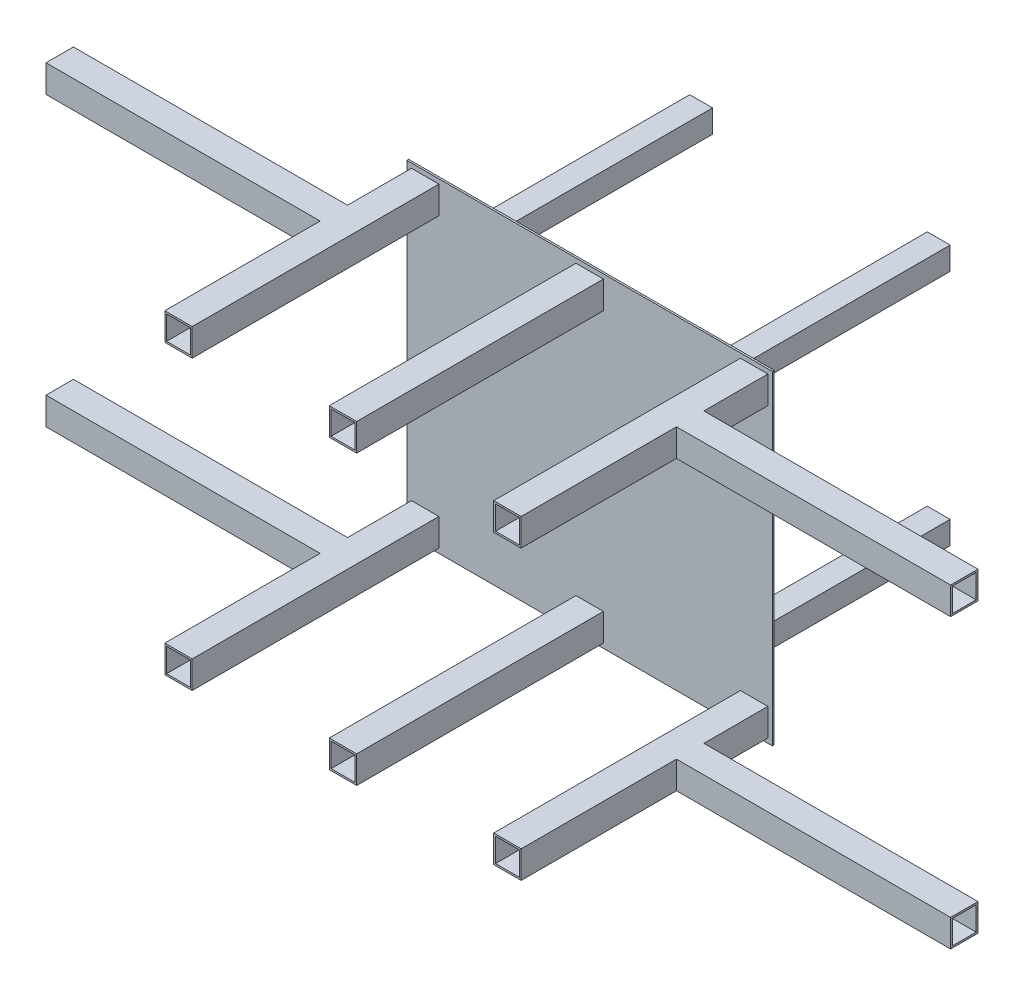
from build123d import *

# Parameters (mm, degrees)
SKETCH_1_W        = 30
SKETCH_1_H        = 30
SKETCH_1_W_2      = 26
SKETCH_1_H_2      = 26
EXTRUDE_1_DEPTH   = 270
EXTRUDE_1_2_DEPTH = 270
EXTRUDE_1_3_DEPTH = 270
EXTRUDE_1_4_DEPTH = 270
EXTRUDE_1_5_DEPTH = 270
EXTRUDE_1_6_DEPTH = 270
SKETCH_1_4_W      = 400
SKETCH_1_4_H      = 355
EXTRUDE_2_DEPTH   = 2
SKETCH_3_W        = 25
SKETCH_3_H        = 25
SKETCH_3_W_2      = 22
SKETCH_3_H_2      = 22
EXTRUDE_3_DEPTH   = 250
SKETCH_8_W        = 30
SKETCH_8_H        = 30
SKETCH_8_W_2      = 26
SKETCH_8_H_2      = 26
EXTRUDE_4_DEPTH   = 300


with BuildPart() as part:
    # 草圖1 → 填料-伸長1 (new body)
    with BuildSketch(Plane.XY):
        with Locations((-139.865693992, 17.660065035)):
            Rectangle(SKETCH_1_W, SKETCH_1_H)
        with Locations((-139.865693992, 17.660065035)):
            Rectangle(SKETCH_1_W_2, SKETCH_1_H_2, mode=Mode.SUBTRACT)
    extrude(amount=EXTRUDE_1_DEPTH)



with BuildPart() as body_2:
    # 草圖1 → Extrude 1 2 (new body)
    with BuildSketch(Plane.XY):
        with Locations((40.134306008, 17.660065035)):
            Rectangle(SKETCH_1_W, SKETCH_1_H)
        with Locations((40.134306008, 17.660065035)):
            Rectangle(SKETCH_1_W_2, SKETCH_1_H_2, mode=Mode.SUBTRACT)
    extrude(amount=EXTRUDE_1_2_DEPTH)


with BuildPart() as body_3:
    # 草圖1 → Extrude 1 3 (new body)
    with BuildSketch(Plane.XY):
        with Locations((220.134306008, 17.660065035)):
            Rectangle(SKETCH_1_W, SKETCH_1_H)
        with Locations((220.134306008, 17.660065035)):
            Rectangle(SKETCH_1_W_2, SKETCH_1_H_2, mode=Mode.SUBTRACT)
    extrude(amount=EXTRUDE_1_3_DEPTH)


with BuildPart() as body_4:
    # 草圖1 → Extrude 1 4 (new body)
    with BuildSketch(Plane.XY):
        with Locations((-139.865693992, -297.339934965)):
            Rectangle(SKETCH_1_W, SKETCH_1_H)
        with Locations((-139.865693992, -297.339934965)):
            Rectangle(SKETCH_1_W_2, SKETCH_1_H_2, mode=Mode.SUBTRACT)
    extrude(amount=EXTRUDE_1_4_DEPTH)


with BuildPart() as body_5:
    # 草圖1 → Extrude 1 5 (new body)
    with BuildSketch(Plane.XY):
        with Locations((40.134306008, -297.339934965)):
            Rectangle(SKETCH_1_W, SKETCH_1_H)
        with Locations((40.134306008, -297.339934965)):
            Rectangle(SKETCH_1_W_2, SKETCH_1_H_2, mode=Mode.SUBTRACT)
    extrude(amount=EXTRUDE_1_5_DEPTH)


with BuildPart() as body_6:
    # 草圖1 → Extrude 1 6 (new body)
    with BuildSketch(Plane.XY):
        with Locations((220.134306008, -297.339934965)):
            Rectangle(SKETCH_1_W, SKETCH_1_H)
        with Locations((220.134306008, -297.339934965)):
            Rectangle(SKETCH_1_W_2, SKETCH_1_H_2, mode=Mode.SUBTRACT)
    extrude(amount=EXTRUDE_1_6_DEPTH)


with BuildPart() as part_1:
    add(part.part)

    add(body_2.part)  # 填料-伸長2 merges body 2

    add(body_3.part)  # 填料-伸長2 merges body 3

    add(body_4.part)  # 填料-伸長2 merges body 4

    add(body_5.part)  # 填料-伸長2 merges body 5

    add(body_6.part)  # 填料-伸長2 merges body 6
    # 草圖1<4> → 填料-伸長2 (add)
    with BuildSketch(Plane.XY):
        with Locations((40.134306008, -139.839934965)):
            Rectangle(SKETCH_1_4_W, SKETCH_1_4_H)
    extrude(amount=-EXTRUDE_2_DEPTH)

    # 草圖3 → 填料-伸長3 (add)
    # profile 1 of 4: a face of its own
    with BuildSketch(Plane(origin=(0, 0, -2), x_dir=(-1, 0, 0), z_dir=(0, 0, -1))):
        with Locations((-170.134306008, -9.839934965)):
            Rectangle(SKETCH_3_W, SKETCH_3_H)
        with Locations((-170.134306008, -9.839934965)):
            Rectangle(SKETCH_3_W_2, SKETCH_3_H_2, mode=Mode.SUBTRACT)
    # profile 2 of 4: a face of its own
    with BuildSketch(Plane(origin=(0, 0, -2), x_dir=(-1, 0, 0), z_dir=(0, 0, -1))):
        with Locations((-170.134306008, -269.839934965)):
            Rectangle(SKETCH_3_W, SKETCH_3_H)
        with Locations((-170.134306008, -269.839934965)):
            Rectangle(SKETCH_3_W_2, SKETCH_3_H_2, mode=Mode.SUBTRACT)
    # profile 3 of 4: a face of its own
    with BuildSketch(Plane(origin=(0, 0, -2), x_dir=(-1, 0, 0), z_dir=(0, 0, -1))):
        with Locations((89.865693992, -269.839934965)):
            Rectangle(SKETCH_3_W, SKETCH_3_H)
        with Locations((89.865693992, -269.839934965)):
            Rectangle(SKETCH_3_W_2, SKETCH_3_H_2, mode=Mode.SUBTRACT)
    # profile 4 of 4: a face of its own
    with BuildSketch(Plane(origin=(0, 0, -2), x_dir=(-1, 0, 0), z_dir=(0, 0, -1))):
        with Locations((89.865693992, -9.839934965)):
            Rectangle(SKETCH_3_W, SKETCH_3_H)
        with Locations((89.865693992, -9.839934965)):
            Rectangle(SKETCH_3_W_2, SKETCH_3_H_2, mode=Mode.SUBTRACT)
    extrude(amount=EXTRUDE_3_DEPTH)

    # 草圖8 → 填料-伸長4 (add)
    # profile 1 of 2: a face of its own
    with BuildSketch(Plane.ZY.offset(154.865693992)):
        with Locations((85, -297.339934965)):
            Rectangle(SKETCH_8_W, SKETCH_8_H)
        with Locations((85, -297.339934965)):
            Rectangle(SKETCH_8_W_2, SKETCH_8_H_2, mode=Mode.SUBTRACT)
    # profile 2 of 2: a face of its own
    with BuildSketch(Plane.ZY.offset(154.865693992)):
        with Locations((85, 17.660065035)):
            Rectangle(SKETCH_8_W, SKETCH_8_H)
        with Locations((85, 17.660065035)):
            Rectangle(SKETCH_8_W_2, SKETCH_8_H_2, mode=Mode.SUBTRACT)
    extrude_4 = extrude(amount=EXTRUDE_4_DEPTH)

    # 鏡射1: 填料-伸長4 across plane
    add(extrude_4.mirror(Plane.ZY.offset(-40.134306008)))


solid = part_1.part
